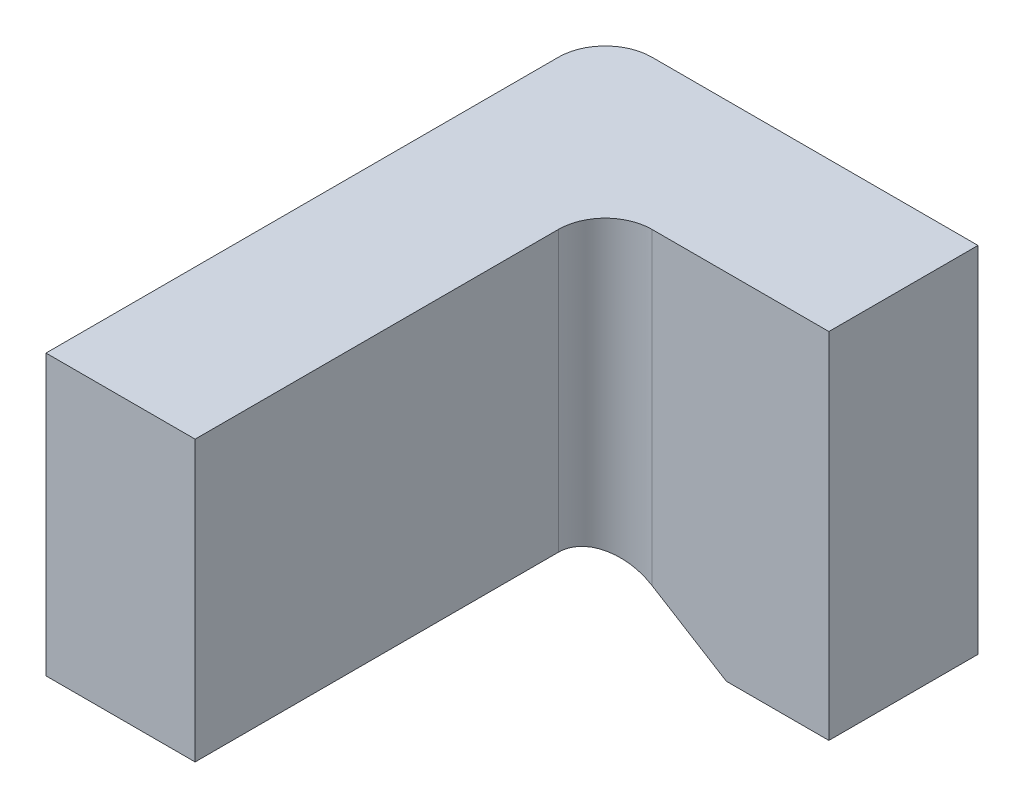
from build123d import *

# Parameters (mm, degrees)
EXTRUDE_1_DEPTH = 0.16
SKETCH_2_W      = 0.16
SKETCH_2_H      = 0.3
EXTRUDE_2_DEPTH = 0.44
FILLET_1_R      = 0.05
FILLET_2_R      = 0.05


with BuildPart() as part:
    # 草图1 → 凸台-拉伸1 (new body)
    with BuildSketch(Plane.XY):
        Polygon((0, 0), (0.4, 0), (0.4, -0.38), (0.29, -0.38), (0.16, -0.3), (0, -0.3), align=None)
    extrude(amount=EXTRUDE_1_DEPTH)

    # 草图2 → 凸台-拉伸2 (add)
    with BuildSketch(Plane.XY.offset(0.16)):
        with Locations((0.08, -0.15)):
            Rectangle(SKETCH_2_W, SKETCH_2_H)
    extrude(amount=EXTRUDE_2_DEPTH)

    # 圆角1
    fillet_1_edges = [part.edges().sort_by_distance(p)[0] for p in [
        (0, -0.15, 0),
    ]]
    fillet(fillet_1_edges, radius=FILLET_1_R)

    # 圆角2
    fillet_2_edges = [part.edges().sort_by_distance(p)[0] for p in [
        (0.16, -0.15, 0.16),
    ]]
    fillet(fillet_2_edges, radius=FILLET_2_R)


solid = part.part
